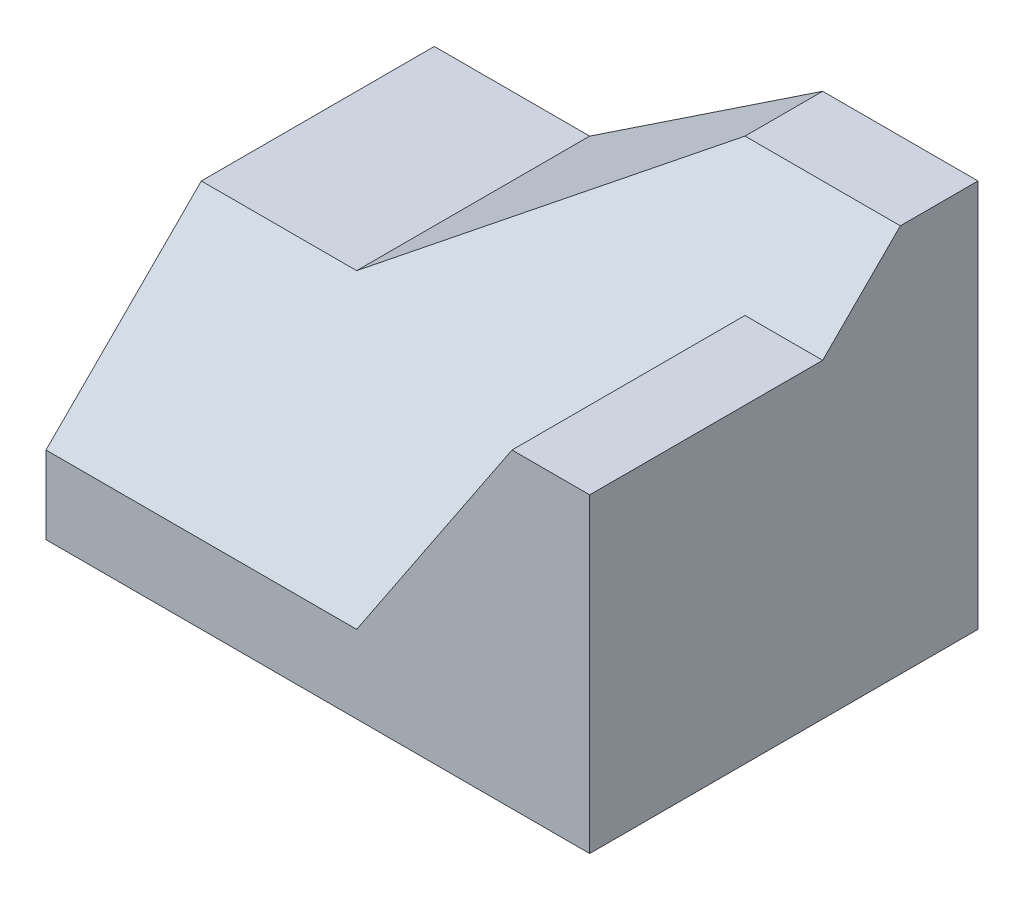
from build123d import *

# Parameters (mm, degrees)
SKETCH1_W           = 70
SKETCH1_H           = 50
BOSS_EXTRUDE1_DEPTH = 50
CUT_EXTRUDE1_DEPTH  = 50
CUT_EXTRUDE2_DEPTH  = 50
CUT_EXTRUDE3_DEPTH  = 30
BOSS_EXTRUDE2_DEPTH = 30
CUT_EXTRUDE4_DEPTH  = 54
SKETCH7_W           = 70
SKETCH7_H           = 50
CUT_EXTRUDE5_DEPTH  = 54
SKETCH8_W           = 70
SKETCH8_H           = 49.997172982
CUT_EXTRUDE6_DEPTH  = 54
BOSS_EXTRUDE3_DEPTH = 30


with BuildPart() as part:
    # Sketch1 → Boss-Extrude1 (new body)
    with BuildSketch(Plane.XY):
        with Locations((35, 25)):
            Rectangle(SKETCH1_W, SKETCH1_H)
    extrude(amount=BOSS_EXTRUDE1_DEPTH)

    # Sketch2 → Cut-Extrude1 (cut)
    with BuildSketch(Plane.XY.offset(50)):
        Polygon((0, 30), (20, 30), (50, 50), (0, 50), align=None)
    extrude(amount=-CUT_EXTRUDE1_DEPTH, mode=Mode.SUBTRACT)

    # Sketch3 → Cut-Extrude2 (cut)
    with BuildSketch(Plane(origin=(70, 0, 0), x_dir=(0, 0, -1), z_dir=(1, 0, 0))):
        Polygon((-50, 40), (-20, 40), (-10, 50), (-50, 50), align=None)
    extrude(amount=-CUT_EXTRUDE2_DEPTH, mode=Mode.SUBTRACT)

    # Sketch4 → Cut-Extrude3 (cut)
    with BuildSketch(Plane.XY.offset(50)):
        Polygon((40, 10), (60, 40), (35, 40), (20, 30), (0, 30), (0, 10), align=None)
    extrude(amount=-CUT_EXTRUDE3_DEPTH, mode=Mode.SUBTRACT)

    # Sketch5 → Boss-Extrude2 (add)
    with BuildSketch(Plane(origin=(0, 30, 30), x_dir=(-1, 0, 0), z_dir=(0, -0.707106781, -0.707106781))):
        Polygon((-70, 28.284271247), (-40, -28.284271247), (0, -28.284271247), (0, 0), (-50, 28.284271247), align=None)
    extrude(amount=BOSS_EXTRUDE2_DEPTH)

    # Sketch6 → Cut-Extrude4 (cut)
    with BuildSketch(Plane(origin=(0, 0, 0), x_dir=(-1, 0, 0), z_dir=(0, 0, -1))):
        Polygon((-50, 50), (-20, 30), (0, 30), (0, 60), (-50, 60), align=None)
    extrude(amount=-CUT_EXTRUDE4_DEPTH, mode=Mode.SUBTRACT)

    # Sketch7 → Cut-Extrude5 (cut)
    with BuildSketch(Plane.XZ):
        with Locations((35, 25)):
            Rectangle(SKETCH7_W, SKETCH7_H)
    extrude(amount=CUT_EXTRUDE5_DEPTH, mode=Mode.SUBTRACT)

    # Sketch8 → Cut-Extrude6 (cut)
    with BuildSketch(Plane(origin=(0, 0, 0), x_dir=(-1, 0, 0), z_dir=(0, 0, -1))):
        with Locations((-35, 24.998586491)):
            Rectangle(SKETCH8_W, SKETCH8_H)
    extrude(amount=CUT_EXTRUDE6_DEPTH, mode=Mode.SUBTRACT)

    # Sketch9 → Boss-Extrude3 (add)
    with BuildSketch(Plane(origin=(0, 30, 0), x_dir=(1, 0, 0), z_dir=(0, 1, 0))):
        Polygon((12.5, -20), (0, -20), (0, -30), align=None)
    extrude(amount=-BOSS_EXTRUDE3_DEPTH)


solid = part.part
